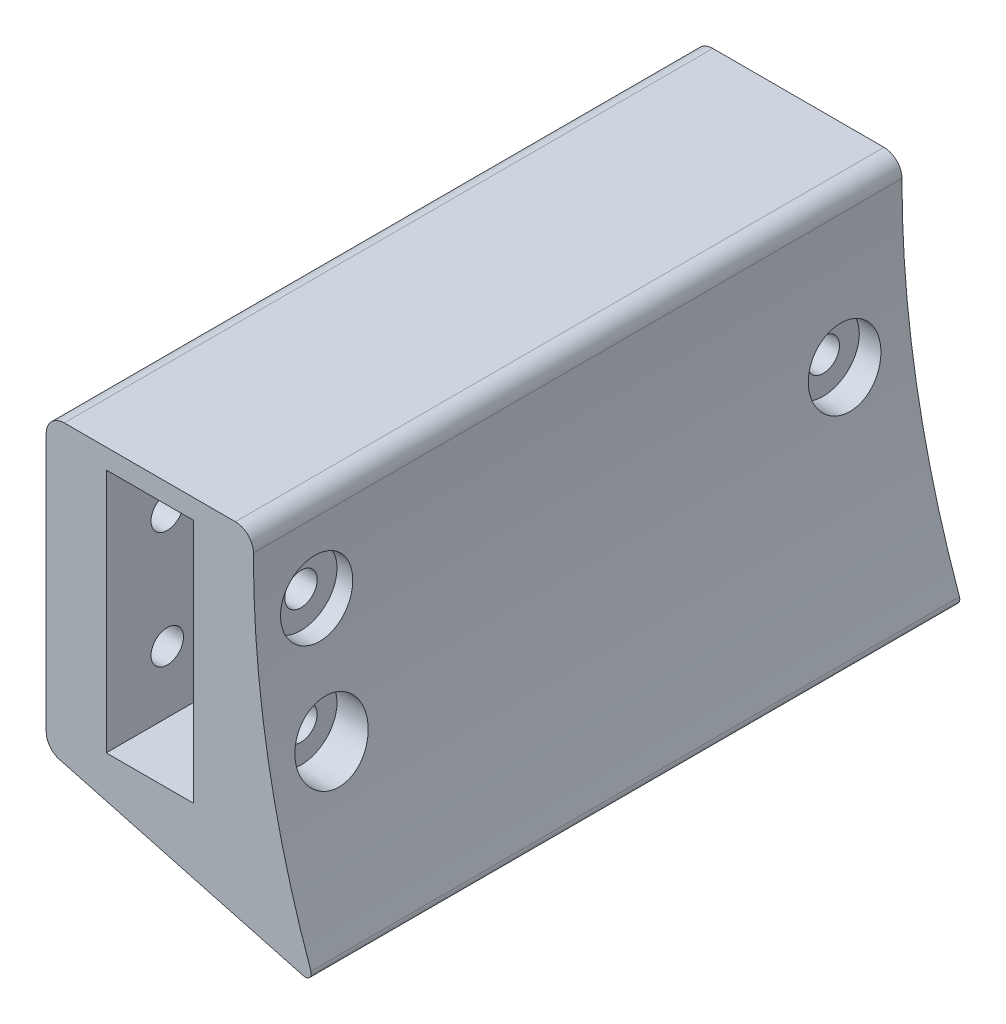
from build123d import *

# Parameters (mm, degrees)
ESQUISSE1_W             = 14.54
ESQUISSE1_H             = 40.8
BOSS_EXTRU_1_DEPTH      = 108
D_GAGEMENT_M1_62_D      = 5.4
CONG_1_R                = 3
CONG_2_R                = 1
ESQUISSE6_R             = 6
ENL_V_MAT_EXTRU_1_DEPTH = 15
ENL_V_MAT_EXTRU_2_DEPTH = 3


with BuildPart() as part:
    # Esquisse1 → Boss.-Extru.1 (new body)
    with BuildSketch(Plane.XY):
        with BuildLine():
            Line((-17.27, 44.084778495), (-17.27, -4.260431004))
            Line((-17.27, -4.260431004), (27.460015919, -16.245802647))
            ThreePointArc((27.460015919, -16.245802647), (19.521650941, 13.439236404), (17.27, 44.084778495))
            Line((17.27, 44.084778495), (-17.27, 44.084778495))
        make_face()
        with Locations((0, 20.4)):
            Rectangle(ESQUISSE1_W, ESQUISSE1_H, mode=Mode.SUBTRACT)
    extrude(amount=BOSS_EXTRU_1_DEPTH)

    # Dégagement M1.62 (through all)
    with Locations(Plane.ZY.offset(17.27)):
        with Locations((10.872493666, 20), (97.844217786, 29.700422986), (97.844217786, 10.299577014)):
            Hole(D_GAGEMENT_M1_62_D / 2)

    # Congé1
    cong_1_edges = [part.edges().sort_by_distance(p)[0] for p in [
        (17.27, 44.084778495, 54),
        (-17.27, -4.260431004, 54),
        (-17.27, 44.084778495, 54),
    ]]
    fillet(cong_1_edges, radius=CONG_1_R)

    # Congé2
    cong_2_edges = [part.edges().sort_by_distance(p)[0] for p in [
        (27.460015919, -16.245802647, 54),
    ]]
    fillet(cong_2_edges, radius=CONG_2_R)

    # Esquisse6 → Enlèv. mat.-Extru.1 (cut)
    with BuildSketch(Plane(origin=(30, 0, 0), x_dir=(0, 0, -1), z_dir=(1, 0, 0))):
        with Locations((-10.872493666, 20)):
            Circle(ESQUISSE6_R)
        with Locations((-97.844217786, 29.700422986)):
            Circle(ESQUISSE6_R)
        with Locations((-97.844217786, 10.299577014)):
            Circle(ESQUISSE6_R)
    extrude(amount=-ENL_V_MAT_EXTRU_1_DEPTH, mode=Mode.SUBTRACT)

    # Esquisse7 → Enlèv. mat.-Extru.2 (cut)
    with BuildSketch(Plane.ZY.offset(17.27)):
        Polygon((13.759245012, 15), (16.645996358, 20), (13.759245012, 25), (7.98574232, 25), (5.098990974, 20), (7.98574232, 15), align=None)
        Polygon((100.730969132, 24.700422986), (103.617720477, 29.700422986), (100.730969132, 34.700422986), (94.95746644, 34.700422986), (92.070715094, 29.700422986), (94.95746644, 24.700422986), align=None)
        Polygon((100.730969132, 5.299577014), (103.617720477, 10.299577014), (100.730969132, 15.299577014), (94.95746644, 15.299577014), (92.070715094, 10.299577014), (94.95746644, 5.299577014), align=None)
    extrude(amount=-ENL_V_MAT_EXTRU_2_DEPTH, mode=Mode.SUBTRACT)


solid = part.part
